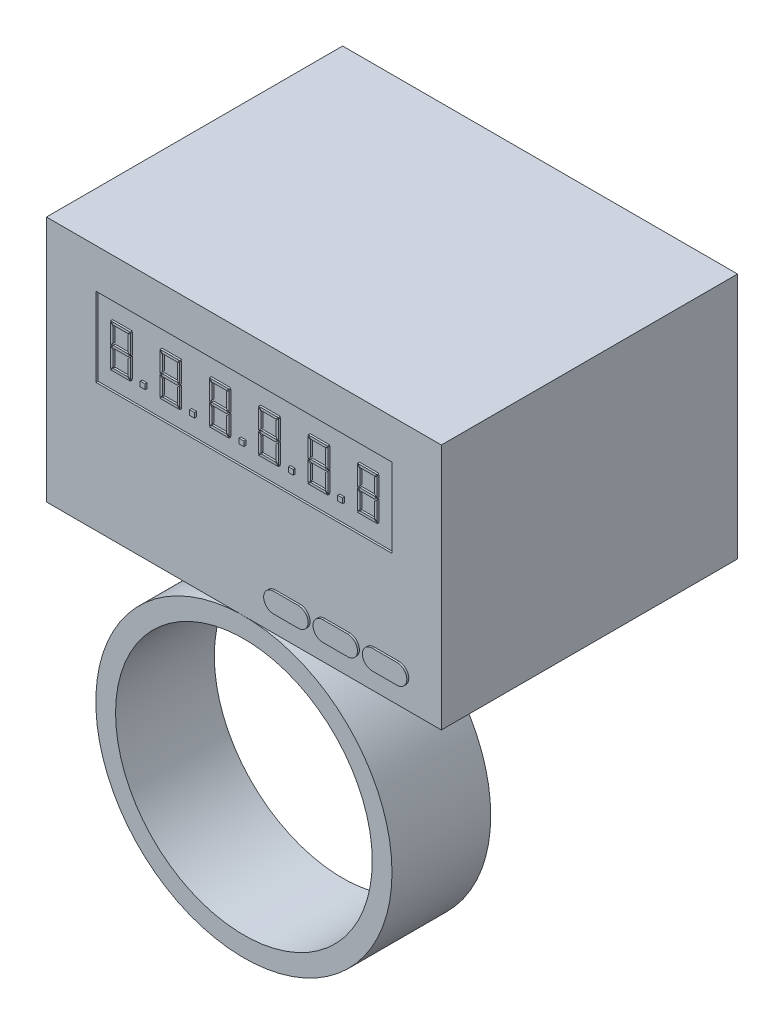
from build123d import *

# Parameters (mm, degrees)
SKETCH_1_W             = 40
SKETCH_1_H             = 25
EXTRUDE_1_DEPTH        = 30
SKETCH_2_W             = 30
SKETCH_2_H             = 8
CUT_EXTRUDE_1_DEPTH    = 0.2
EXTRUDE_2_DEPTH        = 0.2
SKETCH_4_W             = 0.5
SKETCH_4_H             = 0.5
EXTRUDE_3_DEPTH        = 0.2
PATTERN_LINEAR_3_COUNT = 6
PATTERN_LINEAR_3_PITCH = 5
PATTERN_LINEAR_4_COUNT = 5
PATTERN_LINEAR_4_PITCH = 5
EXTRUDE_4_DEPTH        = 0.2
PATTERN_LINEAR_5_COUNT = 3
PATTERN_LINEAR_5_PITCH = 5
SKETCH_6_R             = 15
SKETCH_6_R_2           = 13
EXTRUDE_5_DEPTH        = 10


with BuildPart() as part:
    # 草图1 → 凸台-拉伸1 (new body)
    with BuildSketch(Plane.XY):
        with Locations((-10, 2.5)):
            Rectangle(SKETCH_1_W, SKETCH_1_H)
    extrude(amount=-EXTRUDE_1_DEPTH)

    # 草图2 → 切除-拉伸1 (cut)
    with BuildSketch(Plane.XY):
        with Locations((-10, 7)):
            Rectangle(SKETCH_2_W, SKETCH_2_H)
    extrude(amount=-CUT_EXTRUDE_1_DEPTH, mode=Mode.SUBTRACT)

    # 草图3 → 凸台-拉伸2 (add)
    with BuildSketch(Plane.XY.offset(-0.2)):
        Polygon((-23.5, 9.05), (-23.25, 8.8), (-23.25, 7.3), (-23.5, 7.05), align=None)
        Polygon((-23.5, 9.15), (-21.5, 9.15), (-21.75, 8.9), (-23.25, 8.9), align=None)
        Polygon((-21.75, 7.125), (-23.25, 7.125), (-23.375, 7.002140765), (-23.25, 6.875), (-21.75, 6.875), (-21.625, 7.002140765), align=None)
        Polygon((-21.5, 4.85), (-21.75, 5.1), (-23.25, 5.1), (-23.5, 4.85), align=None)
        Polygon((-23.25, 5.2), (-23.25, 6.7), (-23.5, 6.95), (-23.5, 4.95), align=None)
        Polygon((-21.5, 4.95), (-21.75, 5.2), (-21.75, 6.7), (-21.5, 6.95), align=None)
        Polygon((-21.75, 8.8), (-21.75, 7.3), (-21.5, 7.05), (-21.5, 9.05), align=None)
    extrude_2 = extrude(amount=EXTRUDE_2_DEPTH)

    # 草图4 → 凸台-拉伸3 (add)
    with BuildSketch(Plane.XY.offset(-0.2)):
        with Locations((-20.25, 5.1)):
            Rectangle(SKETCH_4_W, SKETCH_4_H)
    extrude_3 = extrude(amount=EXTRUDE_3_DEPTH)

    # 阵列(线性)3: 凸台-拉伸2 ×6
    with Locations(*[(i * PATTERN_LINEAR_3_PITCH, 0, 0) for i in range(1, PATTERN_LINEAR_3_COUNT)]):
        add(extrude_2)

    # 阵列(线性)4: 凸台-拉伸3 ×5
    with Locations(*[(i * PATTERN_LINEAR_4_PITCH, 0, 0) for i in range(1, PATTERN_LINEAR_4_COUNT)]):
        add(extrude_3)

    # 草图5 → 凸台-拉伸4 (add)
    with BuildSketch(Plane.XY):
        with BuildLine():
            Line((-6.799745803, -6.121830002), (-4.299745803, -6.121830002))
            ThreePointArc((-4.299745803, -6.121830002), (-3.299745803, -7.121830002), (-4.299745803, -8.121830002))
            Line((-4.299745803, -8.121830002), (-6.799745803, -8.121830002))
            ThreePointArc((-6.799745803, -8.121830002), (-7.799745803, -7.121830002), (-6.799745803, -6.121830002))
        make_face()
    extrude_4 = extrude(amount=EXTRUDE_4_DEPTH)

    # 阵列(线性)5: 凸台-拉伸4 ×3
    with Locations(*[(i * PATTERN_LINEAR_5_PITCH, 0, 0) for i in range(1, PATTERN_LINEAR_5_COUNT)]):
        add(extrude_4)


with BuildPart() as body_2:
    # 草图6 → 凸台-拉伸5 (new body)
    with BuildSketch(Plane.XY):
        with Locations((-10, -25)):
            Circle(SKETCH_6_R)
        with Locations((-10, -25)):
            Circle(SKETCH_6_R_2, mode=Mode.SUBTRACT)
    extrude(amount=-EXTRUDE_5_DEPTH)


solid = Compound([part.part, body_2.part])
